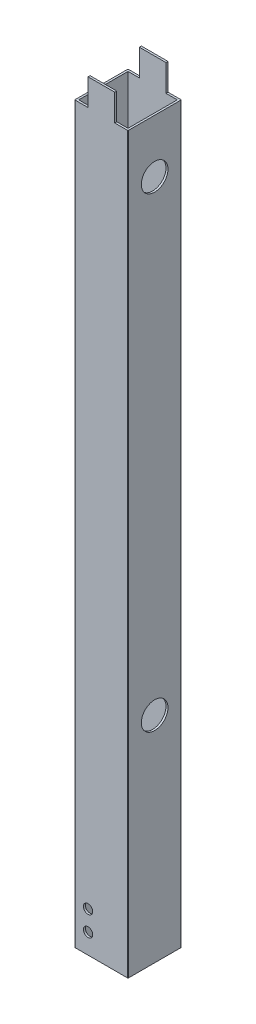
from build123d import *

# Parameters (mm, degrees)
SKETCH1_W           = 37
SKETCH1_H           = 37
BOSS_EXTRUDE1_DEPTH = 571
SKETCH2_W           = 10
SKETCH2_H           = 20
CUT_EXTRUDE1_DEPTH  = 40
CUT_EXTRUDE2_START  = -20
SKETCH3_W           = 21
SKETCH3_H           = 2
CUT_EXTRUDE2_DEPTH  = 20
CUT_EXTRUDE3_DEPTH  = 20
SKETCH5_R           = 3.5
CUT_EXTRUDE4_DEPTH  = 10
SKETCH6_R           = 10
CUT_EXTRUDE5_DEPTH  = 574.795259653


with BuildPart() as part:
    # Sketch1 → Boss-Extrude1 (new body)
    with BuildSketch(Plane(origin=(0, 0, 0), x_dir=(1, 0, 0), z_dir=(0, 1, 0))):
        with BuildLine():
            Line((0.5, 0), (39.5, 0))
            ThreePointArc((39.5, 0), (39.853553391, 0.146446609), (40, 0.5))
            Line((40, 0.5), (40, 39.5))
            ThreePointArc((40, 39.5), (39.853553391, 39.853553391), (39.5, 40))
            Line((39.5, 40), (0.5, 40))
            ThreePointArc((0.5, 40), (0.146446609, 39.853553391), (0, 39.5))
            Line((0, 39.5), (0, 0.5))
            ThreePointArc((0, 0.5), (0.146446609, 0.146446609), (0.5, 0))
        make_face()
        with Locations((20, 20)):
            Rectangle(SKETCH1_W, SKETCH1_H, mode=Mode.SUBTRACT)
    extrude(amount=BOSS_EXTRUDE1_DEPTH)

    # Sketch2 → Cut-Extrude1 (cut)
    with BuildSketch(Plane.XY.offset(-40)):
        with Locations((35, 561)):
            Rectangle(SKETCH2_W, SKETCH2_H)
        with Locations((5, 561)):
            Rectangle(SKETCH2_W, SKETCH2_H)
    extrude(amount=CUT_EXTRUDE1_DEPTH, mode=Mode.SUBTRACT)

    # Sketch3 → Cut-Extrude2 (cut)
    with BuildSketch(Plane(origin=(40, 0, 0), x_dir=(0, 0, -1), z_dir=(1, 0, 0)).offset(CUT_EXTRUDE2_START)):
        with Locations((29.5, 467.5)):
            Rectangle(SKETCH3_W, SKETCH3_H)
        with Locations((29.5, 429.5)):
            Rectangle(SKETCH3_W, SKETCH3_H)
    extrude(amount=-CUT_EXTRUDE2_DEPTH, mode=Mode.SUBTRACT)

    # Sketch4 → Cut-Extrude3 (cut)
    with BuildSketch(Plane(origin=(0, 0, -40), x_dir=(-1, 0, 0), z_dir=(0, 0, -1))):
        Polygon((-4.773301235, 47.75), (-7.273301235, 52.080127019), (-3, 54.547318637), (-3, 56.279369445), (0, 56.279369445), (0, 48.773815945), (-3, 48.773815945), align=None)
        Polygon((0, 66.094324021), (0, 73.59987752), (-3, 73.59987752), (-3, 71.867826713), (-14.340288533, 65.320508076), (-11.840288533, 60.990381057), (-3, 66.094324021), align=None)
    extrude(amount=-CUT_EXTRUDE3_DEPTH, mode=Mode.SUBTRACT)

    # Sketch5 → Cut-Extrude4 (cut)
    with BuildSketch(Plane.XY):
        with Locations((10, 15)):
            Circle(SKETCH5_R)
        with Locations((10, 30)):
            Circle(SKETCH5_R)
    extrude(amount=-CUT_EXTRUDE4_DEPTH, mode=Mode.SUBTRACT)

    # Sketch6 → Cut-Extrude5 (cut, through all)
    with BuildSketch(Plane.ZY):
        with Locations((-20, 511)):
            Circle(SKETCH6_R)
        with Locations((-20, 161)):
            Circle(SKETCH6_R)
    extrude(amount=-CUT_EXTRUDE5_DEPTH, mode=Mode.SUBTRACT)


solid = part.part
